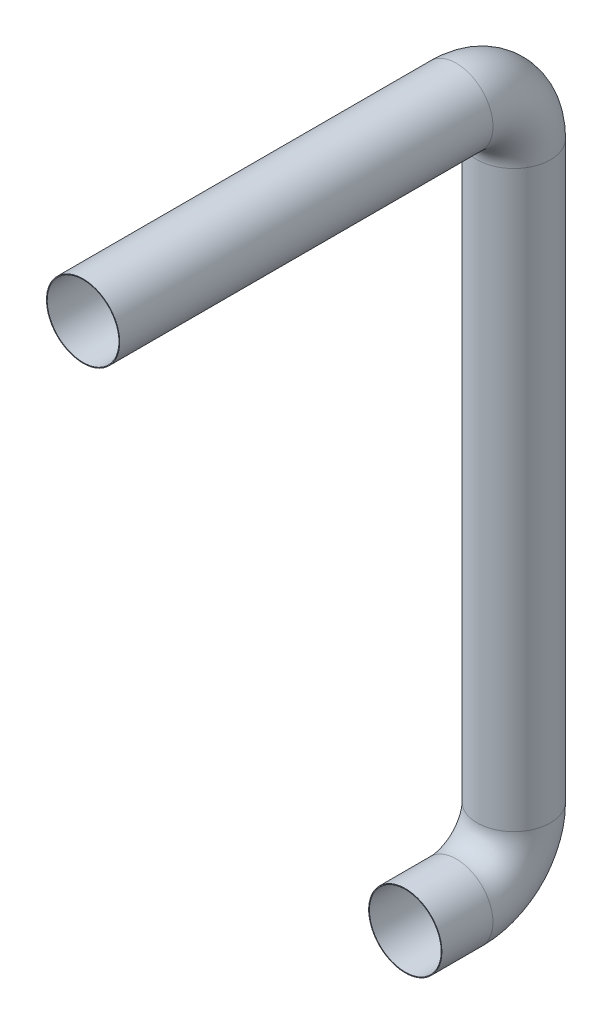
from build123d import *

# Parameters (mm, degrees)
SKETCH31_R   = 25.5
SKETCH31_R_2 = 25


with BuildPart() as part:
    # Sweep1: sweep along a path in Sketch3
    with BuildLine(Plane(origin=(0, 0, 0), x_dir=(0, 0, -1), z_dir=(1, 0, 0))) as sweep1_path:
        Line((0, 0), (260, 0))
        ThreePointArc((260, 0), (288.284271247, -11.715728753), (300, -40))
        Line((300, -40), (300, -440))
        ThreePointArc((300, -440), (288.284271247, -468.284271247), (260, -480))
        Line((260, -480), (224.43, -480))
    # Sketch31 → Sweep1 (sweep)
    with BuildSketch(Plane.XY):
        Circle(SKETCH31_R)
        Circle(SKETCH31_R_2, mode=Mode.SUBTRACT)
    sweep(path=sweep1_path.line)


solid = part.part
